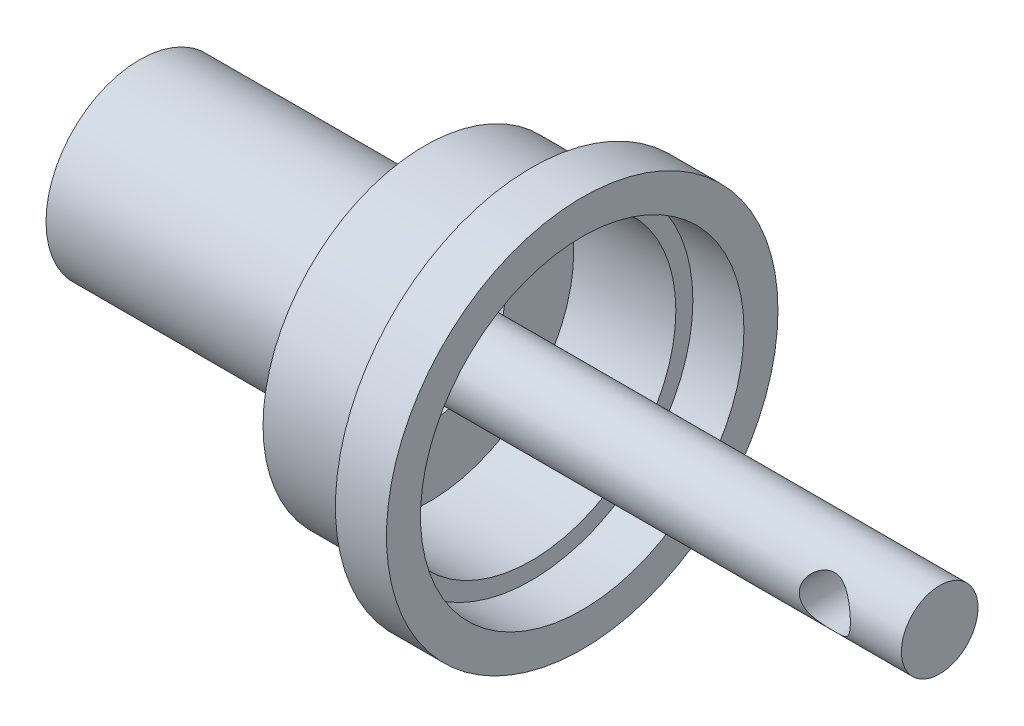
from build123d import *

# Parameters (mm, degrees)
SKETCH1_R               = 5.5
BOSS_EXTRUDE1_DEPTH     = 5
SKETCH2_R               = 5.5
SKETCH2_R_2             = 4.5
BOSS_EXTRUDE2_DEPTH     = 12
SKETCH3_R               = 2.25
BOSS_EXTRUDE3_DEPTH     = 42
SKETCH4_R               = 9.5
SKETCH4_R_2             = 8.5
BOSS_EXTRUDE4_DEPTH     = 6
SKETCH5_R               = 9.5
BOSS_EXTRUDE5_DEPTH     = 0.25
SKETCH6_R               = 11.5
SKETCH6_R_2             = 9.5
BOSS_EXTRUDE6_DEPTH     = 3
SKETCH7_R               = 1.5
CUT_EXTRUDE1_DEPTH      = 12.5
CUT_EXTRUDE1_DEPTH_BACK = 12.5
SKETCH9_R               = 4.5
SKETCH9_R_2             = 2.25
CUT_EXTRUDE3_DEPTH      = 1


with BuildPart() as part:
    # Sketch1 → Boss-Extrude1 (new body)
    with BuildSketch(Plane(origin=(0, 0, 0), x_dir=(0, 0, -1), z_dir=(1, 0, 0))):
        Circle(SKETCH1_R)
    extrude(amount=BOSS_EXTRUDE1_DEPTH)

    # Sketch2 → Boss-Extrude2 (add)
    with BuildSketch(Plane(origin=(5, 0, 0), x_dir=(0, 0, -1), z_dir=(1, 0, 0))):
        Circle(SKETCH2_R)
        Circle(SKETCH2_R_2, mode=Mode.SUBTRACT)
    extrude(amount=BOSS_EXTRUDE2_DEPTH)

    # Sketch3 → Boss-Extrude3 (add)
    with BuildSketch(Plane(origin=(5, 0, 0), x_dir=(0, 0, -1), z_dir=(1, 0, 0))):
        Circle(SKETCH3_R)
    extrude(amount=BOSS_EXTRUDE3_DEPTH)



with BuildPart() as body_2:
    # Sketch4 → Boss-Extrude4 (new body)
    with BuildSketch(Plane(origin=(17, 0, 0), x_dir=(0, 0, -1), z_dir=(1, 0, 0))):
        Circle(SKETCH4_R)
        Circle(SKETCH4_R_2, mode=Mode.SUBTRACT)
    extrude(amount=BOSS_EXTRUDE4_DEPTH)


with BuildPart() as part_1:
    add(part.part)

    add(body_2.part)  # Boss-Extrude5 merges body 2
    # Sketch5 → Boss-Extrude5 (add)
    with BuildSketch(Plane.ZY.offset(-17)):
        Circle(SKETCH5_R)
    extrude(amount=BOSS_EXTRUDE5_DEPTH)

    # Sketch7 → Cut-Extrude1 (cut, two sides)
    with BuildSketch(Plane.XY) as cut_extrude1_sk:
        with Locations((42.5, 0)):
            Circle(SKETCH7_R)
    extrude(amount=CUT_EXTRUDE1_DEPTH, mode=Mode.SUBTRACT)
    extrude(cut_extrude1_sk.sketch, amount=-CUT_EXTRUDE1_DEPTH_BACK, mode=Mode.SUBTRACT)

    # Sketch9 → Cut-Extrude3 (cut)
    with BuildSketch(Plane(origin=(17, 0, 0), x_dir=(0, 0, -1), z_dir=(1, 0, 0))):
        Circle(SKETCH9_R)
        Circle(SKETCH9_R_2, mode=Mode.SUBTRACT)
    extrude(amount=-CUT_EXTRUDE3_DEPTH, mode=Mode.SUBTRACT)


with BuildPart() as body_2_2:
    # Sketch6 → Boss-Extrude6 (new body)
    with BuildSketch(Plane(origin=(23, 0, 0), x_dir=(0, 0, -1), z_dir=(1, 0, 0))):
        Circle(SKETCH6_R)
        Circle(SKETCH6_R_2, mode=Mode.SUBTRACT)
    extrude(amount=BOSS_EXTRUDE6_DEPTH)


solid = Compound([part_1.part, body_2_2.part])
